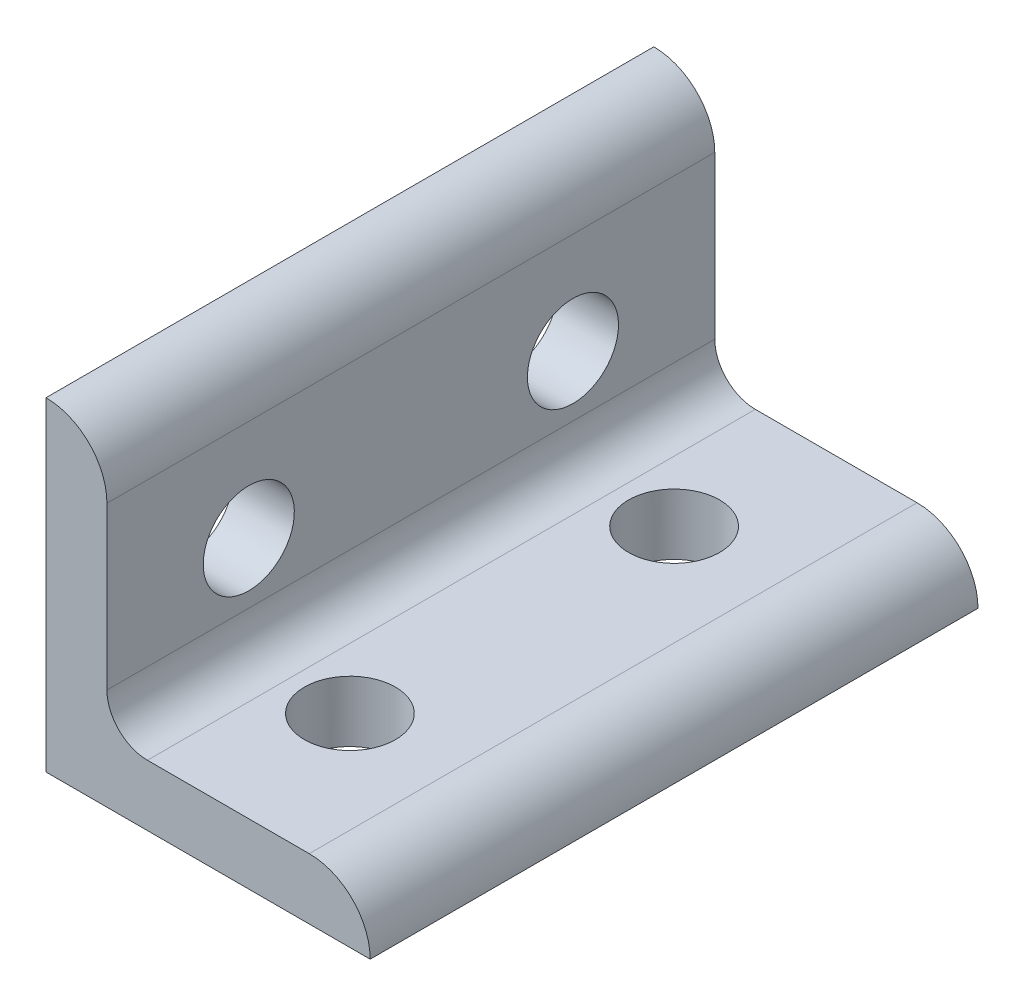
from build123d import *

# Parameters (mm, degrees)
BOSS_EXTRUDE1_DEPTH = 23.8125
SKETCH2_R           = 3.5687
CUT_EXTRUDE1_DEPTH  = 26.4
SKETCH3_R           = 3.5687
CUT_EXTRUDE2_DEPTH  = 26.4


with BuildPart() as part:
    # Sketch1 → Boss-Extrude1 (new body, symmetric)
    with BuildSketch(Plane.XY):
        with BuildLine():
            Line((0, 0), (0, 25.4))
            ThreePointArc((0, 25.4), (3.376576302, 24.001376302), (4.7752, 20.6248))
            Line((4.7752, 20.6248), (4.7752, 7.9502))
            ThreePointArc((4.7752, 7.9502), (5.70513597, 5.70513597), (7.9502, 4.7752))
            Line((7.9502, 4.7752), (20.6248, 4.7752))
            ThreePointArc((20.6248, 4.7752), (24.001376302, 3.376576302), (25.4, 0))
            Line((25.4, 0), (0, 0))
        make_face()
    extrude(amount=BOSS_EXTRUDE1_DEPTH, both=True)

    # Sketch2 → Cut-Extrude1 (cut, through all)
    with BuildSketch(Plane(origin=(0, 0, 0), x_dir=(1, 0, 0), z_dir=(0, 1, 0))):
        with Locations((12.7, -12.7)):
            Circle(SKETCH2_R)
        with Locations((12.7, 12.7)):
            Circle(SKETCH2_R)
    extrude(amount=CUT_EXTRUDE1_DEPTH, mode=Mode.SUBTRACT)

    # Sketch3 → Cut-Extrude2 (cut, through all)
    with BuildSketch(Plane(origin=(0, 0, 0), x_dir=(0, 0, -1), z_dir=(1, 0, 0))):
        with Locations((-12.7, 12.7)):
            Circle(SKETCH3_R)
        with Locations((12.7, 12.7)):
            Circle(SKETCH3_R)
    extrude(amount=CUT_EXTRUDE2_DEPTH, mode=Mode.SUBTRACT)


solid = part.part
